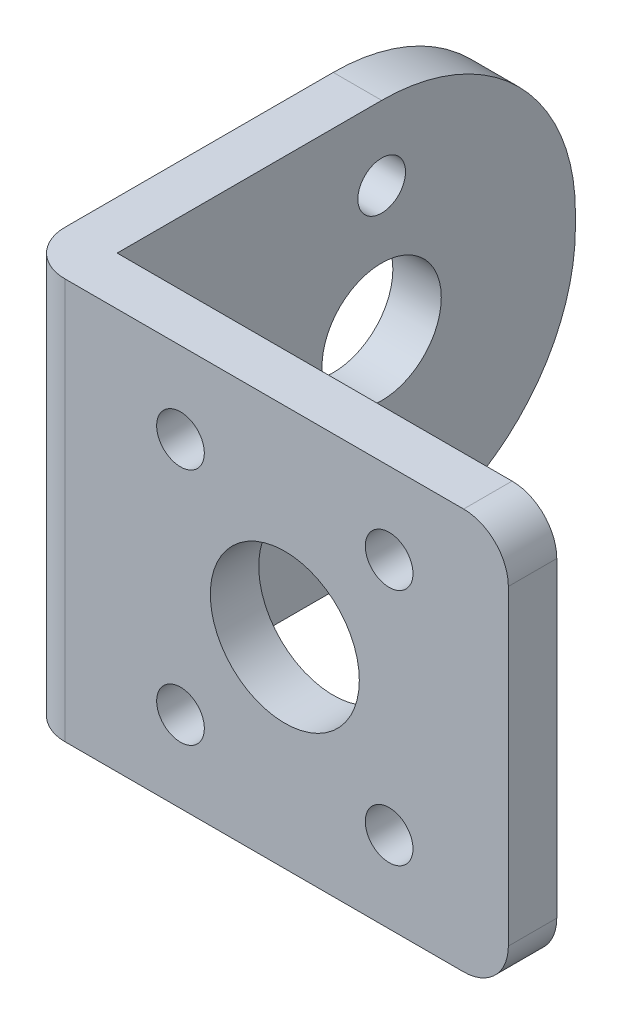
from build123d import *

# Parameters (mm, degrees)
SKETCH1_W           = 32.75
SKETCH1_H           = 26.9
BOSS_EXTRUDE1_DEPTH = 3.25
FILLET1_R           = 3
SKETCH2_R           = 5
SKETCH2_R_2         = 1.6
CUT_EXTRUDE1_DEPTH  = 3.25
SKETCH4_W           = 3.25
SKETCH4_H           = 26.9
BOSS_EXTRUDE2_DEPTH = 30.75
FILLET2_R           = 3
SKETCH5_R           = 4
SKETCH5_R_2         = 1.6
CUT_EXTRUDE2_DEPTH  = 30.75
FILLET4_R           = 13


with BuildPart() as part:
    # Sketch1 → Boss-Extrude1 (new body)
    with BuildSketch(Plane.XY):
        with Locations((16.375, 13.45)):
            Rectangle(SKETCH1_W, SKETCH1_H)
    extrude(amount=BOSS_EXTRUDE1_DEPTH)

    # Fillet1
    fillet1_edges = [part.edges().sort_by_distance(p)[0] for p in [
        (32.75, 26.9, 1.625),
        (32.75, 0, 1.625),
    ]]
    fillet(fillet1_edges, radius=FILLET1_R)

    # Sketch2 → Cut-Extrude1 (cut)
    with BuildSketch(Plane.XY.offset(3.25)):
        with BuildLine():
            ThreePointArc((12.35, 21.45), (9.61862915, 22.58137085), (10.75, 19.85))
            Line((10.75, 19.85), (10.75, 21.45))
            Line((10.75, 21.45), (12.35, 21.45))
        make_face()
        with BuildLine():
            Line((10.75, 21.45), (10.75, 19.85))
            ThreePointArc((10.75, 19.85), (11.88137085, 20.31862915), (12.35, 21.45))
            Line((12.35, 21.45), (10.75, 21.45))
        make_face()
        with Locations((17.75, 13.45)):
            Circle(SKETCH2_R)
        with Locations((24.75, 21.45)):
            Circle(SKETCH2_R_2)
        with Locations((24.75, 5.45)):
            Circle(SKETCH2_R_2)
        with Locations((10.75, 5.45)):
            Circle(SKETCH2_R_2)
    extrude(amount=-CUT_EXTRUDE1_DEPTH, mode=Mode.SUBTRACT)

    # Sketch4 → Boss-Extrude2 (add)
    with BuildSketch(Plane(origin=(0, 0, 0), x_dir=(-1, 0, 0), z_dir=(0, 0, -1))):
        with Locations((-1.625, 13.45)):
            Rectangle(SKETCH4_W, SKETCH4_H)
    extrude(amount=BOSS_EXTRUDE2_DEPTH)

    # Fillet2
    fillet2_edges = [part.edges().sort_by_distance(p)[0] for p in [
        (0, 13.45, 3.25),
    ]]
    fillet(fillet2_edges, radius=FILLET2_R)

    # Sketch5 → Cut-Extrude2 (cut)
    with BuildSketch(Plane(origin=(3.25, 0, 0), x_dir=(0, 0, -1), z_dir=(1, 0, 0))):
        with Locations((17.75, 13.45)):
            Circle(SKETCH5_R)
        with Locations((17.75, 21.95)):
            Circle(SKETCH5_R_2)
        with Locations((17.75, 4.95)):
            Circle(SKETCH5_R_2)
    extrude(amount=-CUT_EXTRUDE2_DEPTH, mode=Mode.SUBTRACT)

    # Fillet4
    fillet4_edges = [part.edges().sort_by_distance(p)[0] for p in [
        (1.625, 26.9, -30.75),
        (1.625, 0, -30.75),
    ]]
    fillet(fillet4_edges, radius=FILLET4_R)


solid = part.part
